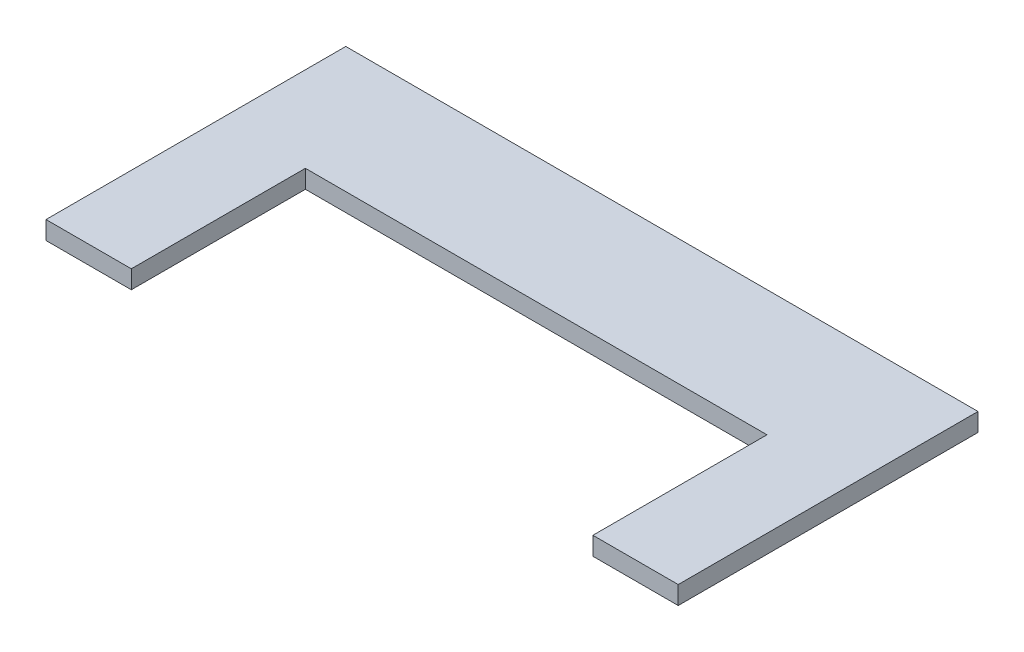
from build123d import *

# Parameters (mm, degrees)
BOSS_EXTRUDE1_DEPTH = 3.2


with BuildPart() as part:
    # Sketch1 → Boss-Extrude1 (new body)
    with BuildSketch(Plane(origin=(0, 0, 0), x_dir=(1, 0, 0), z_dir=(0, 1, 0))):
        Polygon((-55.572217102, 52.7), (55.572217102, 52.7), (55.572217102, 0), (40.572217102, 0), (40.572217102, 30.6), (-40.572217102, 30.6), (-40.572217102, 0), (-55.572217102, 0), align=None)
    extrude(amount=BOSS_EXTRUDE1_DEPTH)


solid = part.part
